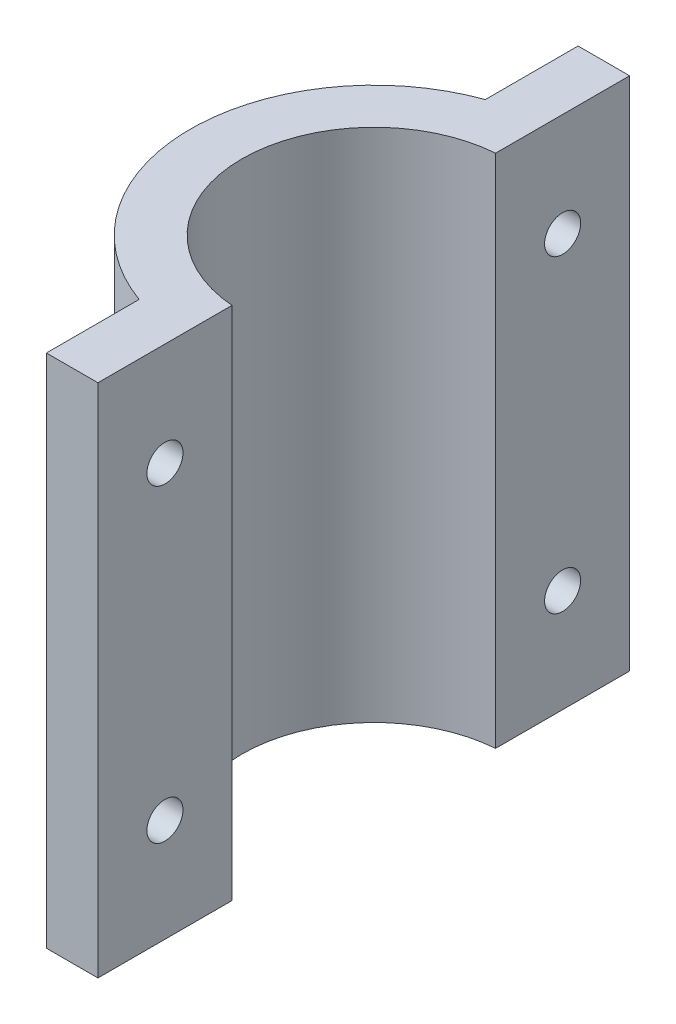
from build123d import *

# Parameters (mm, degrees)
BOSS_EXTRUDE4_DEPTH = 50
SKETCH7_R           = 1.75
CUT_EXTRUDE1_DEPTH  = 17.825


with BuildPart() as part:
    # Sketch6 → Boss-Extrude4 (new body)
    with BuildSketch(Plane.XZ):
        with BuildLine():
            Line((-1, 25.784833184), (-1, 12.785954208))
            ThreePointArc((-1, 12.785954208), (-12.825, 0), (-1, -12.785954208))
            Line((-1, -12.785954208), (-1, -25.784833184))
            Line((-1, -25.784833184), (-6, -25.784833184))
            Line((-6, -25.784833184), (-6, -16.784833184))
            ThreePointArc((-6, -16.784833184), (-17.825, 0), (-6, 16.784833184))
            Line((-6, 16.784833184), (-6, 25.784833184))
            Line((-6, 25.784833184), (-1, 25.784833184))
        make_face()
    extrude(amount=BOSS_EXTRUDE4_DEPTH)

    # Sketch7 → Cut-Extrude1 (cut, through all)
    with BuildSketch(Plane(origin=(-1, 0, 0), x_dir=(0, 0, -1), z_dir=(1, 0, 0))):
        with Locations((-19.285393696, -10)):
            Circle(SKETCH7_R)
        with Locations((-19.285393696, -40)):
            Circle(SKETCH7_R)
        with Locations((19.285393696, -40)):
            Circle(SKETCH7_R)
        with Locations((19.285393696, -10)):
            Circle(SKETCH7_R)
    extrude(amount=-CUT_EXTRUDE1_DEPTH, mode=Mode.SUBTRACT)


solid = part.part
